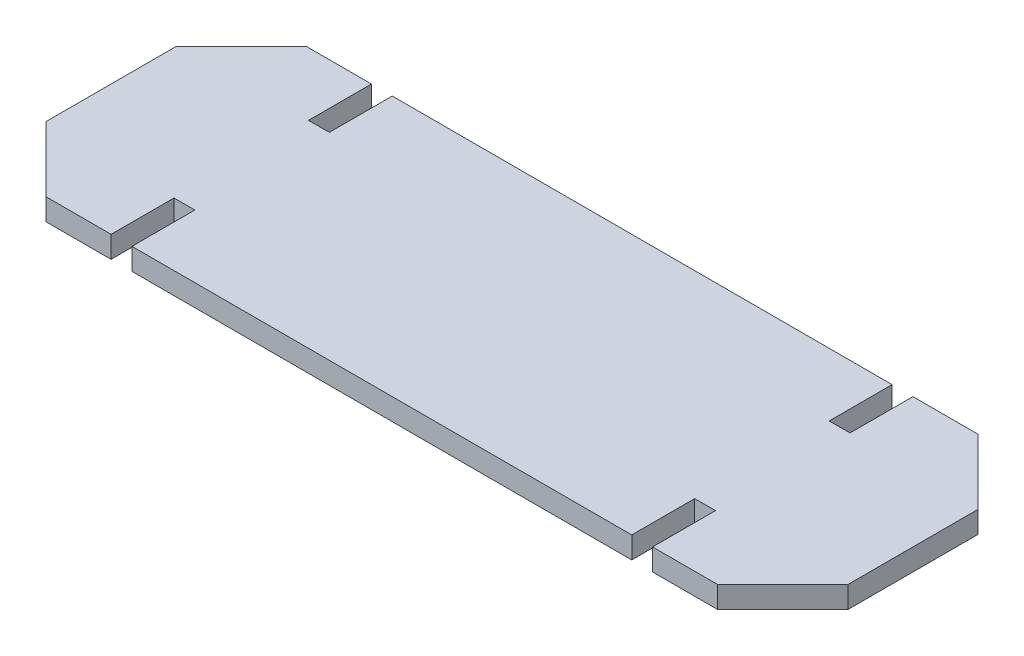
from build123d import *

# Parameters (mm, degrees)
BOSS_EXTRUDE1_DEPTH = 12.7


with BuildPart() as part:
    # Sketch1 → Boss-Extrude1 (new body)
    with BuildSketch(Plane(origin=(0, 0, 0), x_dir=(1, 0, 0), z_dir=(0, 1, 0))):
        Polygon((-196.596, 76.2), (-234.696, 38.1), (-234.696, -38.1), (-196.596, -76.2), (-158.496, -76.2), (-158.496, -39.37), (-146.304, -39.37), (-146.304, -76.2), (146.304, -76.2), (146.304, -39.37), (158.496, -39.37), (158.496, -76.2), (196.596, -76.2), (234.696, -38.1), (234.696, 38.1), (196.596, 76.2), (158.496, 76.2), (158.496, 39.37), (146.304, 39.37), (146.304, 76.2), (-146.304, 76.2), (-146.304, 39.37), (-158.496, 39.37), (-158.496, 76.2), align=None)
    extrude(amount=BOSS_EXTRUDE1_DEPTH)


solid = part.part
